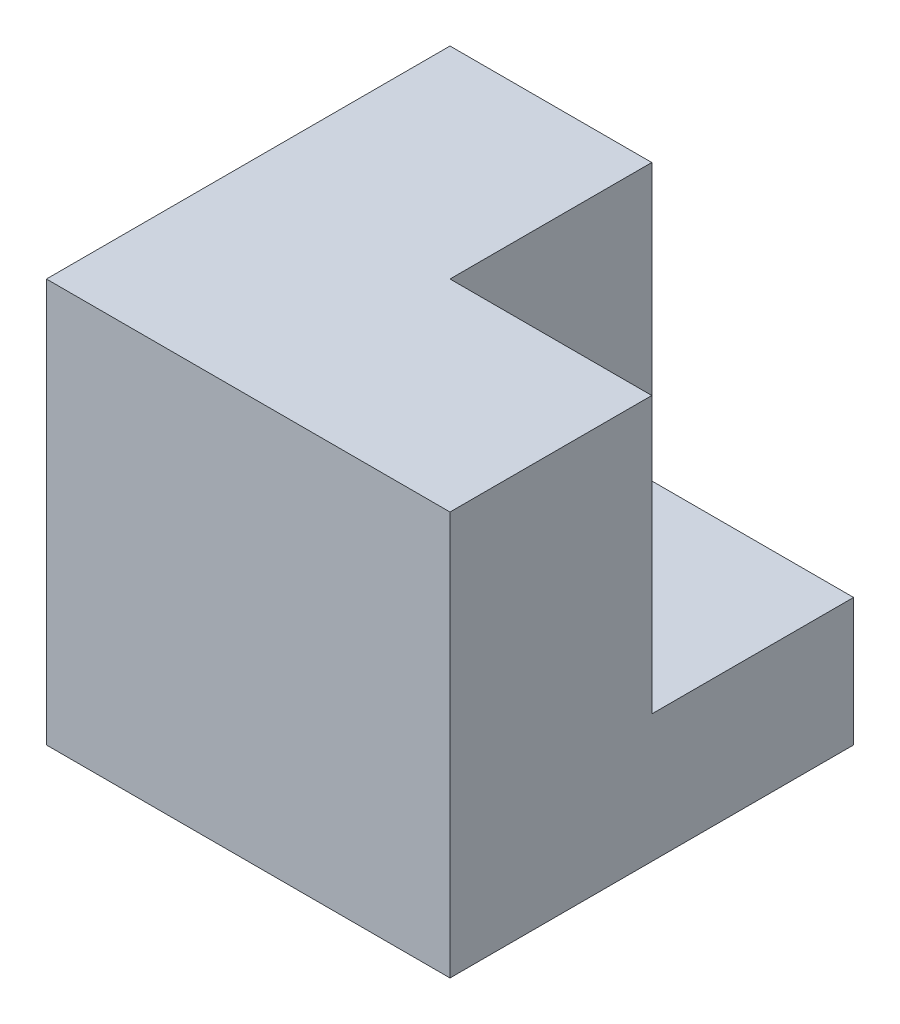
from build123d import *

# Parameters (mm, degrees)
SKETCH1_W           = 76.2
SKETCH1_H           = 76.2
BOSS_EXTRUDE1_DEPTH = 76.2
SKETCH2_W           = 38.1
SKETCH2_H           = 52.07
CUT_EXTRUDE1_DEPTH  = 38.1


with BuildPart() as part:
    # Sketch1 → Boss-Extrude1 (new body)
    with BuildSketch(Plane.XY):
        with Locations((38.1, 38.1)):
            Rectangle(SKETCH1_W, SKETCH1_H)
    extrude(amount=BOSS_EXTRUDE1_DEPTH)

    # Sketch2 → Cut-Extrude1 (cut)
    with BuildSketch(Plane(origin=(76.2, 0, 0), x_dir=(0, 0, -1), z_dir=(1, 0, 0))):
        with Locations((-19.05, 50.165)):
            Rectangle(SKETCH2_W, SKETCH2_H)
    extrude(amount=-CUT_EXTRUDE1_DEPTH, mode=Mode.SUBTRACT)


solid = part.part
